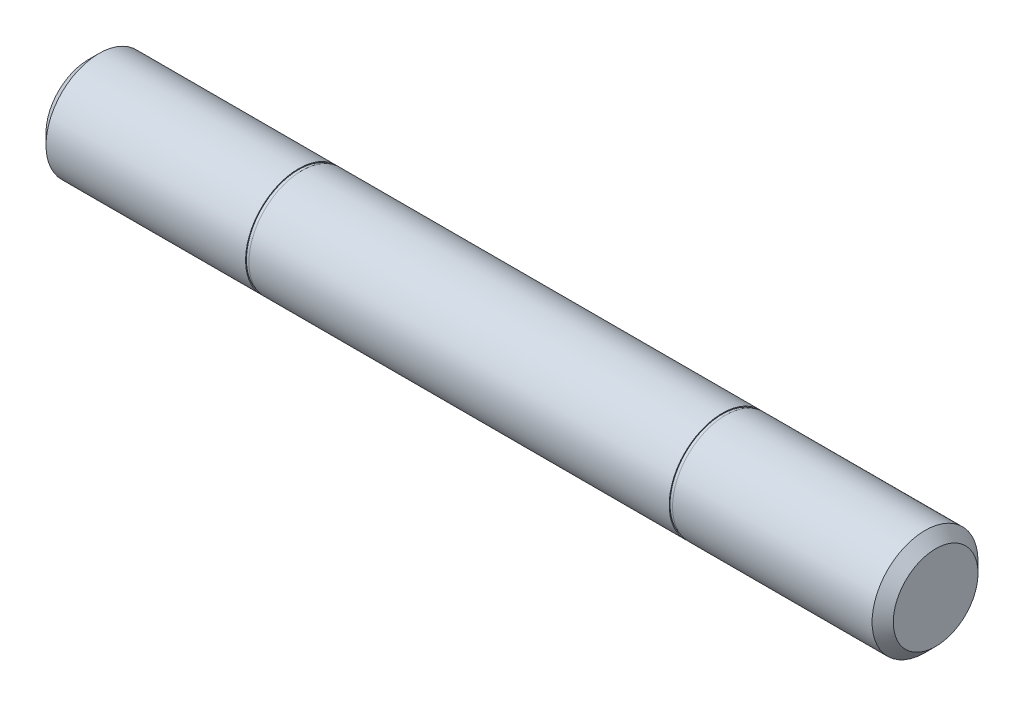
from build123d import *

# Parameters (mm, degrees)
SKETCH2_R           = 1.5875
EXTRUDE1_DEPTH      = 12.7
EXTRUDE1_DEPTH_BACK = 12.7
CHAMFER1_SIZE       = 0.3175
SKETCH4_R           = 1.5875
SKETCH4_R_2         = 1.5621
CUT_EXTRUDE2_DEPTH  = 0.05
SKETCH5_R           = 1.5875
SKETCH5_R_2         = 1.5621
CUT_EXTRUDE3_DEPTH  = 0.05


with BuildPart() as part:
    # Sketch2 → Extrude1 (new body, two sides)
    with BuildSketch(Plane(origin=(0, 0, 0), x_dir=(0, 0, -1), z_dir=(1, 0, 0))) as extrude1_sk:
        Circle(SKETCH2_R)
    extrude(amount=EXTRUDE1_DEPTH)
    extrude(extrude1_sk.sketch, amount=-EXTRUDE1_DEPTH_BACK)

    # Chamfer1
    chamfer1_edges = [part.edges().sort_by_distance(p)[0] for p in [
        (-12.7, 0, 1.5875),
        (12.7, 0, 1.5875),
    ]]
    chamfer(chamfer1_edges, length=CHAMFER1_SIZE)

    # Sketch4 → Cut-Extrude2 (cut, symmetric)
    with BuildSketch(Plane.ZY.offset(6.35)):
        Circle(SKETCH4_R)
        Circle(SKETCH4_R_2, mode=Mode.SUBTRACT)
    extrude(amount=CUT_EXTRUDE2_DEPTH, both=True, mode=Mode.SUBTRACT)

    # Sketch5 → Cut-Extrude3 (cut, symmetric)
    with BuildSketch(Plane(origin=(6.35, 0, 0), x_dir=(0, 0, -1), z_dir=(1, 0, 0))):
        Circle(SKETCH5_R)
        Circle(SKETCH5_R_2, mode=Mode.SUBTRACT)
    extrude(amount=CUT_EXTRUDE3_DEPTH, both=True, mode=Mode.SUBTRACT)


solid = part.part
